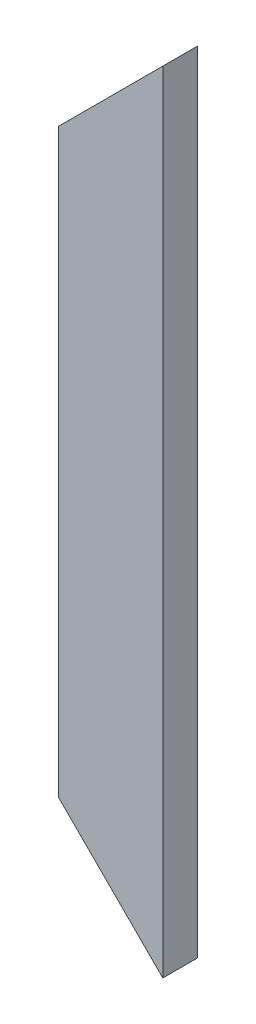
from build123d import *

# Parameters (mm, degrees)
SKETCH1_W               = 76.2
SKETCH1_H               = 25.4
SKETCH1_W_2             = 70.104
SKETCH1_H_2             = 19.304
BOSS_EXTRUDE1_DEPTH     = 500
SKETCH3_W               = 76.2
SKETCH3_H               = 25.4
SKETCH3_W_2             = 70.104
SKETCH3_H_2             = 19.304
BOSS_EXTRUDE2_DEPTH     = 38.1
SKETCH4_W               = 76.2
SKETCH4_H               = 25.4
SKETCH4_W_2             = 70.104
SKETCH4_H_2             = 19.304
BOSS_EXTRUDE3_DEPTH     = 38.1
CUT_EXTRUDE1_DEPTH      = 13.7
CUT_EXTRUDE1_DEPTH_BACK = 13.7
CUT_EXTRUDE2_DEPTH      = 13.7
CUT_EXTRUDE2_DEPTH_BACK = 13.7


with BuildPart() as part:
    # Sketch1 → Boss-Extrude1 (new body)
    with BuildSketch(Plane(origin=(0, 0, 0), x_dir=(1, 0, 0), z_dir=(0, 1, 0))):
        Rectangle(SKETCH1_W, SKETCH1_H)
        Rectangle(SKETCH1_W_2, SKETCH1_H_2, mode=Mode.SUBTRACT)
    extrude(amount=BOSS_EXTRUDE1_DEPTH)

    # Sketch3 → Boss-Extrude2 (add)
    with BuildSketch(Plane.XZ):
        Rectangle(SKETCH3_W, SKETCH3_H)
        Rectangle(SKETCH3_W_2, SKETCH3_H_2, mode=Mode.SUBTRACT)
    extrude(amount=BOSS_EXTRUDE2_DEPTH)

    # Sketch4 → Boss-Extrude3 (add)
    with BuildSketch(Plane(origin=(0, 500, 0), x_dir=(1, 0, 0), z_dir=(0, 1, 0))):
        Rectangle(SKETCH4_W, SKETCH4_H)
        Rectangle(SKETCH4_W_2, SKETCH4_H_2, mode=Mode.SUBTRACT)
    extrude(amount=BOSS_EXTRUDE3_DEPTH)

    # Sketch5 → Cut-Extrude1 (cut, two sides)
    with BuildSketch(Plane.XY) as cut_extrude1_sk:
        Polygon((-62.772673854, 62.772673854), (63.030718061, -63.030718061), (-91.484443541, -186.384573668), (-217.287835457, -60.581181752), align=None)
    extrude(amount=CUT_EXTRUDE1_DEPTH, mode=Mode.SUBTRACT)
    extrude(cut_extrude1_sk.sketch, amount=-CUT_EXTRUDE1_DEPTH_BACK, mode=Mode.SUBTRACT)

    # Sketch6 → Cut-Extrude2 (cut, two sides)
    with BuildSketch(Plane.YX) as cut_extrude2_sk:
        Polygon((393.890988206, -106.109011794), (558.855850204, 58.855850204), (555.016088259, -106.109011794), align=None)
    extrude(amount=CUT_EXTRUDE2_DEPTH, mode=Mode.SUBTRACT)
    extrude(cut_extrude2_sk.sketch, amount=-CUT_EXTRUDE2_DEPTH_BACK, mode=Mode.SUBTRACT)


solid = part.part
